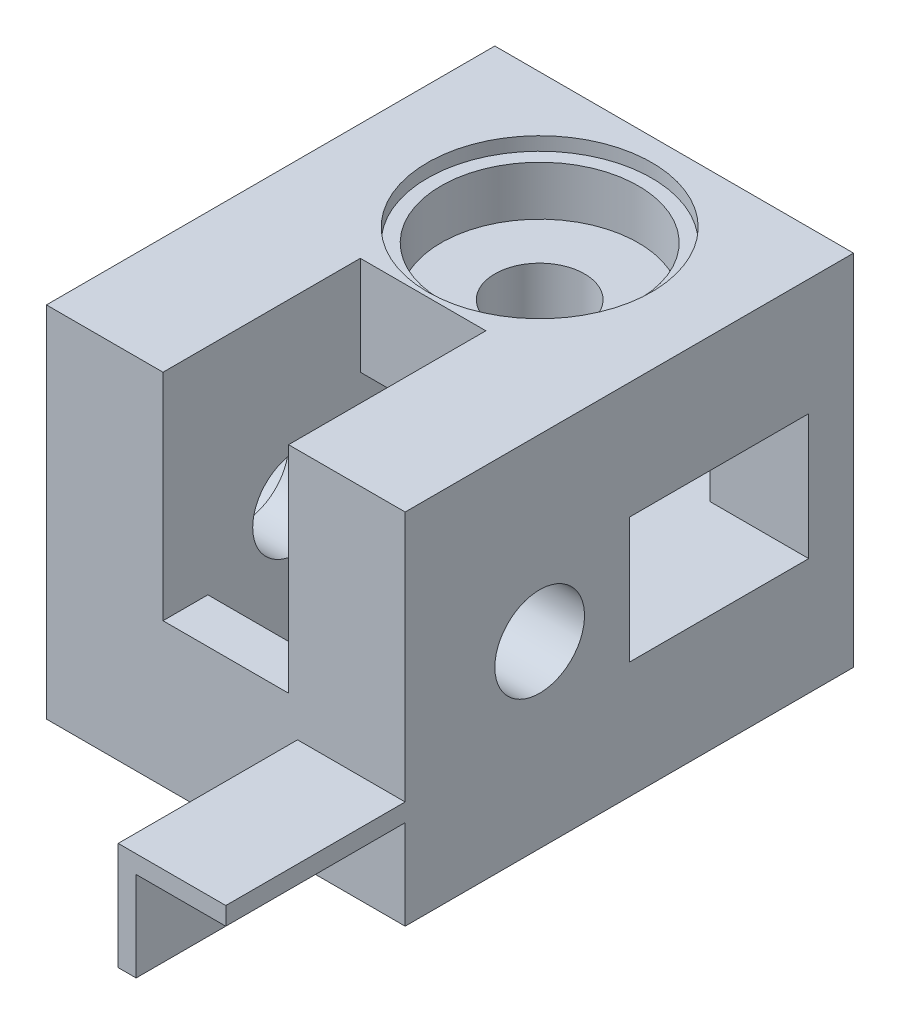
from build123d import *

# Parameters (mm, degrees)
ESQUISSE1_W              = 40
ESQUISSE1_H              = 40
BOSS_EXTRU_1_DEPTH       = 50
ESQUISSE2_R              = 5
ENL_V_MAT_EXTRU_1_DEPTH  = 41
ESQUISSE3_R              = 5
ENL_V_MAT_EXTRU_2_DEPTH  = 41
ESQUISSE4_W              = 22
ESQUISSE4_H              = 14
ENL_V_MAT_EXTRU_3_DEPTH  = 29
ESQUISSE5_W              = 14
ESQUISSE5_H              = 20
ENL_V_MAT_EXTRU_4_DEPTH  = 29
ESQUISSE6_W              = 20
ESQUISSE6_H              = 14
ENL_V_MAT_EXTRU_5_DEPTH  = 24
ESQUISSE7_W              = 14
ESQUISSE7_H              = 22
ENL_V_MAT_EXTRU_6_DEPTH  = 24
ESQUISSE10_R             = 11
ENL_V_MAT_EXTRU_9_DEPTH  = 7
ESQUISSE11_R             = 12.5
ENL_V_MAT_EXTRU_10_DEPTH = 1.5
BOSS_EXTRU_2_DEPTH       = 20
ESQUISSE14_R             = 11
ENL_V_MAT_EXTRU_11_DEPTH = 7
ESQUISSE15_R             = 12.5
ENL_V_MAT_EXTRU_12_DEPTH = 1.5


with BuildPart() as part:
    # Esquisse1 → Boss.-Extru.1 (new body)
    with BuildSketch(Plane.XY):
        with Locations((-20, 20)):
            Rectangle(ESQUISSE1_W, ESQUISSE1_H)
    extrude(amount=BOSS_EXTRU_1_DEPTH)

    # Esquisse2 → Enlèv. mat.-Extru.1 (cut, through all)
    with BuildSketch(Plane(origin=(0, 40, 0), x_dir=(1, 0, 0), z_dir=(0, 1, 0))):
        with Locations(Location((-20, -15, 0), (0, 0, 270))):  # turned: the seam where the file's is
            Circle(ESQUISSE2_R)
    extrude(amount=-ENL_V_MAT_EXTRU_1_DEPTH, mode=Mode.SUBTRACT)

    # Esquisse3 → Enlèv. mat.-Extru.2 (cut, through all)
    with BuildSketch(Plane.ZY.offset(40)):
        with Locations((35, 20)):
            Circle(ESQUISSE3_R)
    extrude(amount=-ENL_V_MAT_EXTRU_2_DEPTH, mode=Mode.SUBTRACT)

    # Esquisse4 → Enlèv. mat.-Extru.3 (cut)
    with BuildSketch(Plane.ZY.offset(40)):
        with Locations((11, 20)):
            Rectangle(ESQUISSE4_W, ESQUISSE4_H)
    extrude(amount=-ENL_V_MAT_EXTRU_3_DEPTH, mode=Mode.SUBTRACT)

    # Esquisse5 → Enlèv. mat.-Extru.4 (cut)
    with BuildSketch(Plane.XZ):
        with Locations((-20, 35)):
            Rectangle(ESQUISSE5_W, ESQUISSE5_H)
    extrude(amount=-ENL_V_MAT_EXTRU_4_DEPTH, mode=Mode.SUBTRACT)

    # Esquisse6 → Enlèv. mat.-Extru.5 (cut)
    with BuildSketch(Plane(origin=(0, 0, 0), x_dir=(0, 0, -1), z_dir=(1, 0, 0))):
        with Locations((-15, 20)):
            Rectangle(ESQUISSE6_W, ESQUISSE6_H)
    extrude(amount=-ENL_V_MAT_EXTRU_5_DEPTH, mode=Mode.SUBTRACT)

    # Esquisse7 → Enlèv. mat.-Extru.6 (cut)
    with BuildSketch(Plane(origin=(0, 40, 0), x_dir=(1, 0, 0), z_dir=(0, 1, 0))):
        with Locations((-20, -39)):
            Rectangle(ESQUISSE7_W, ESQUISSE7_H)
    extrude(amount=-ENL_V_MAT_EXTRU_6_DEPTH, mode=Mode.SUBTRACT)

    # Esquisse10 → Enlèv. mat.-Extru.9 (cut)
    with BuildSketch(Plane(origin=(0, 40, 0), x_dir=(1, 0, 0), z_dir=(0, 1, 0))):
        with Locations(Location((-20, -15, 0), (0, 0, 270))):  # turned: the seam where the file's is
            Circle(ESQUISSE10_R)
    extrude(amount=-ENL_V_MAT_EXTRU_9_DEPTH, mode=Mode.SUBTRACT)

    # Esquisse11 → Enlèv. mat.-Extru.10 (cut)
    with BuildSketch(Plane(origin=(0, 40, 0), x_dir=(1, 0, 0), z_dir=(0, 1, 0))):
        with Locations(Location((-20, -15, 0), (0, 0, 270))):  # turned: the seam where the file's is
            Circle(ESQUISSE11_R)
    extrude(amount=-ENL_V_MAT_EXTRU_10_DEPTH, mode=Mode.SUBTRACT)

    # Esquisse13 → Boss.-Extru.2 (add)
    with BuildSketch(Plane.XY.offset(50)):
        Polygon((-10, 0), (-10, 10), (0, 10), (0, 12), (-12, 12), (-12, 0), align=None)
    extrude(amount=BOSS_EXTRU_2_DEPTH)

    # Esquisse14 → Enlèv. mat.-Extru.11 (cut)
    with BuildSketch(Plane.ZY.offset(40)):
        with Locations((35, 20)):
            Circle(ESQUISSE14_R)
    extrude(amount=-ENL_V_MAT_EXTRU_11_DEPTH, mode=Mode.SUBTRACT)

    # Esquisse15 → Enlèv. mat.-Extru.12 (cut)
    with BuildSketch(Plane.ZY.offset(40)):
        with Locations((35, 20)):
            Circle(ESQUISSE15_R)
    extrude(amount=-ENL_V_MAT_EXTRU_12_DEPTH, mode=Mode.SUBTRACT)


solid = part.part
